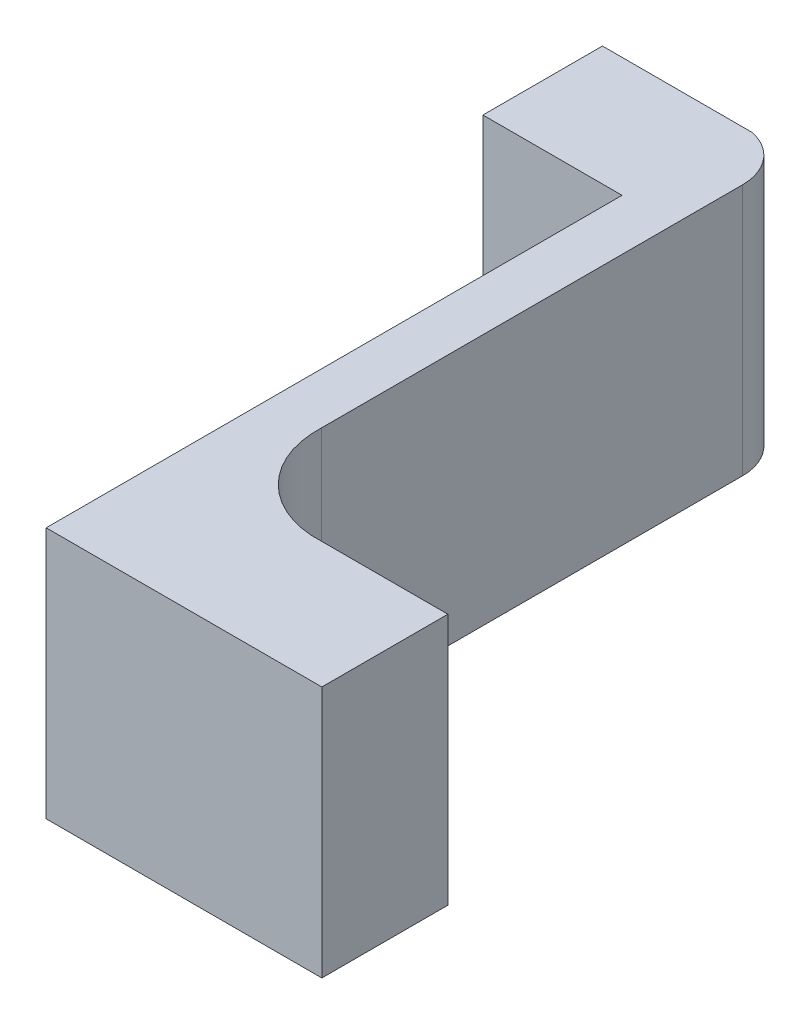
from build123d import *

# Parameters (mm, degrees)
BOSS_EXTRUDE2_DEPTH = 0.4


with BuildPart() as part:
    # Sketch1 → Boss-Extrude2 (new body)
    with BuildSketch(Plane(origin=(0, 0, 0), x_dir=(1, 0, 0), z_dir=(0, 1, 0))):
        with BuildLine():
            Line((0.378997958, -1.040203981), (0.162867241, -1.040203981))
            ThreePointArc((0.162867241, -1.040203981), (0.065400257, -0.995788853), (0.022652214, -0.897579274))
            ThreePointArc((0.022652214, -0.897579274), (0.02250618, -0.890972759), (0.022652214, -0.884366245))
            Line((0.022652214, -0.884366245), (0.022652214, -0.215915587))
            ThreePointArc((0.022652214, -0.215915587), (0.004689259, -0.164992849), (-0.041248332, -0.136610975))
            Line((-0.041248332, -0.136610975), (-0.279282769, -0.136610975))
            Line((-0.279282769, -0.136610975), (-0.279282769, -0.326283695))
            Line((-0.279282769, -0.326283695), (-0.058509075, -0.326283695))
            Line((-0.058509075, -0.326283695), (-0.058509075, -1.240203981))
            Line((-0.058509075, -1.240203981), (0.202867241, -1.240203981))
            Line((0.202867241, -1.240203981), (0.378997958, -1.240203981))
            Line((0.378997958, -1.240203981), (0.378997958, -1.040203981))
        make_face()
    extrude(amount=BOSS_EXTRUDE2_DEPTH)


solid = part.part
